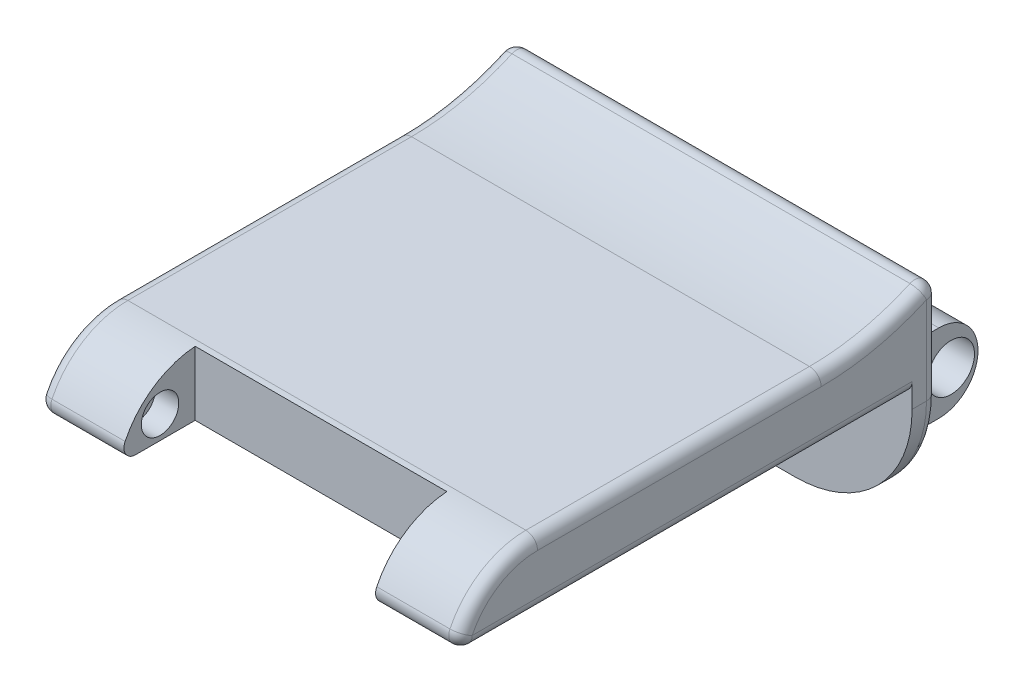
from build123d import *

# Parameters (mm, degrees)
BOSS_EXTRUDE1_DEPTH     = 18
SKETCH2_W               = 21.5
SKETCH2_H               = 6.5
CUT_EXTRUDE1_DEPTH      = 36
FILLET1_R               = 1
FILLET2_R               = 10
SKETCH3_R               = 1.6
CUT_EXTRUDE2_DEPTH      = 23
CUT_EXTRUDE2_DEPTH_BACK = 2
SKETCH4_W               = 11.8
SKETCH4_H               = 6.7
BOSS_EXTRUDE2_DEPTH     = 5.6
CUT_EXTRUDE3_DEPTH      = 34.8
SKETCH6_R               = 2
CUT_EXTRUDE4_DEPTH      = 34.8
SKETCH7_W               = 33.22
SKETCH7_H               = 24.2
CUT_EXTRUDE5_DEPTH      = 1
M1_6_TAPPED_HOLE1_D     = 1.25
M1_6_TAPPED_HOLE1_DEPTH = 3
M1_6_TAPPED_HOLE1_TIP   = 0.375537887
FILLET3_R               = 1
FILLET4_R               = 1


with BuildPart() as part:
    # Sketch1 → Boss-Extrude1 (new body, symmetric)
    with BuildSketch(Plane(origin=(0, 0, 0), x_dir=(0, 0, -1), z_dir=(1, 0, 0))):
        with BuildLine():
            Line((-16.23, 0), (22.77, 0))
            Line((22.77, 0), (22.77, -11.06))
            Line((22.77, -11.06), (25, -11.06))
            Line((25, -11.06), (25, 8.04))
            ThreePointArc((25, 8.04), (20.158769233, 6.144924279), (15, 5.5))
            Line((15, 5.5), (-9.23, 5.5))
            ThreePointArc((-9.23, 5.5), (-13.681123454, 3.960520759), (-16.23, 0))
        make_face()
    extrude(amount=BOSS_EXTRUDE1_DEPTH, both=True)

    # Sketch2 → Cut-Extrude1 (cut)
    with BuildSketch(Plane(origin=(0, 5.5, 0), x_dir=(1, 0, 0), z_dir=(0, 1, 0))):
        with Locations((0, -12.98)):
            Rectangle(SKETCH2_W, SKETCH2_H)
    extrude(amount=-CUT_EXTRUDE1_DEPTH, mode=Mode.SUBTRACT)

    # Fillet1
    fillet1_edges = [part.edges().sort_by_distance(p)[0] for p in [
        (0, 8.04, -25),
    ]]
    fillet(fillet1_edges, radius=FILLET1_R)

    # Fillet2
    fillet2_edges = [part.edges().sort_by_distance(p)[0] for p in [
        (18, -11.06, -23.885),
        (-18, -11.06, -23.885),
    ]]
    fillet(fillet2_edges, radius=FILLET2_R)

    # Sketch3 → Cut-Extrude2 (cut, two sides)
    with BuildSketch(Plane(origin=(-10.75, 0, 0), x_dir=(0, 0, -1), z_dir=(1, 0, 0))) as cut_extrude2_sk:
        with Locations((-12.73, 1.9826289)):
            Circle(SKETCH3_R)
    extrude(amount=CUT_EXTRUDE2_DEPTH, mode=Mode.SUBTRACT)
    extrude(cut_extrude2_sk.sketch, amount=-CUT_EXTRUDE2_DEPTH_BACK, mode=Mode.SUBTRACT)

    # Sketch4 → Boss-Extrude2 (add)
    with BuildSketch(Plane(origin=(0, 0, -25), x_dir=(-1, 0, 0), z_dir=(0, 0, -1))):
        with Locations((-9.9, -1.720538118)):
            Rectangle(SKETCH4_W, SKETCH4_H)
        with Locations((9.9, -1.720538118)):
            Rectangle(SKETCH4_W, SKETCH4_H)
    extrude(amount=BOSS_EXTRUDE2_DEPTH)

    # Sketch5 → Cut-Extrude3 (cut, through all)
    with BuildSketch(Plane(origin=(15.8, 0, 0), x_dir=(0, 0, -1), z_dir=(1, 0, 0))):
        with BuildLine():
            Line((30.6, -1.720538118), (30.6, 1.629461882))
            Line((30.6, 1.629461882), (27.25, 1.629461882))
            ThreePointArc((27.25, 1.629461882), (29.618807717, 0.648269599), (30.6, -1.720538118))
        make_face()
        with BuildLine():
            Line((30.6, -5.070538118), (30.6, -1.720538118))
            ThreePointArc((30.6, -1.720538118), (29.618807717, -4.089345835), (27.25, -5.070538118))
            Line((27.25, -5.070538118), (30.6, -5.070538118))
        make_face()
    extrude(amount=-CUT_EXTRUDE3_DEPTH, mode=Mode.SUBTRACT)

    # Sketch6 → Cut-Extrude4 (cut, through all)
    with BuildSketch(Plane(origin=(15.8, 0, 0), x_dir=(0, 0, -1), z_dir=(1, 0, 0))):
        with Locations((28.302174941, -1.820538118)):
            Circle(SKETCH6_R)
    extrude(amount=-CUT_EXTRUDE4_DEPTH, mode=Mode.SUBTRACT)

    # Sketch7 → Cut-Extrude5 (cut)
    with BuildSketch(Plane.XZ):
        with Locations((0, -3.47)):
            Rectangle(SKETCH7_W, SKETCH7_H)
    extrude(amount=-CUT_EXTRUDE5_DEPTH, mode=Mode.SUBTRACT)

    # M1.6 Tapped Hole1
    with Locations(Plane(origin=(0, 1, 0), x_dir=(-1, 0, 0), z_dir=(0, -1, 0))):
        with Locations((9.7, 5.27), (-9.7, 5.27)):
            Hole(M1_6_TAPPED_HOLE1_D / 2, depth=M1_6_TAPPED_HOLE1_DEPTH)
            with Locations((0, 0, -(M1_6_TAPPED_HOLE1_DEPTH + M1_6_TAPPED_HOLE1_TIP / 2))):  # 118° drill point
                Cone(0, M1_6_TAPPED_HOLE1_D / 2, M1_6_TAPPED_HOLE1_TIP, mode=Mode.SUBTRACT)

    # Fillet3
    fillet3_edges = [part.edges().sort_by_distance(p)[0] for p in [
        (14.375, 0, 16.23),
        (-14.375, 0, 16.23),
    ]]
    fillet(fillet3_edges, radius=FILLET3_R)

    # Fillet4
    fillet4_edges = [part.edges().sort_by_distance(p)[0] for p in [
        (-18, 0, -3.977965877),
        (18, 0, -3.977965877),
        (-18, 0.468914995, 15.661386792),
        (18, 0.468914995, 15.661386792),
        (18, 5.5, -2.885),
        (18, 4.399999523, 13.056226055),
        (-18, 5.96556671, -19.392628497),
        (18, 5.96556671, -19.392628497),
        (-18, 7.269083423, -24.543171858),
        (18, 7.269083423, -24.543171858),
        (0, -11.06, -25),
        (-18, 2.684730941, -25),
        (18, 2.684730941, -25),
        (15.071067812, -8.131067812, -25),
        (-15.071067812, -8.131067812, -25),
        (-18, 5.5, -2.885),
        (-18, 4.399999523, 13.056226055),
    ]]
    fillet(fillet4_edges, radius=FILLET4_R)


solid = part.part
